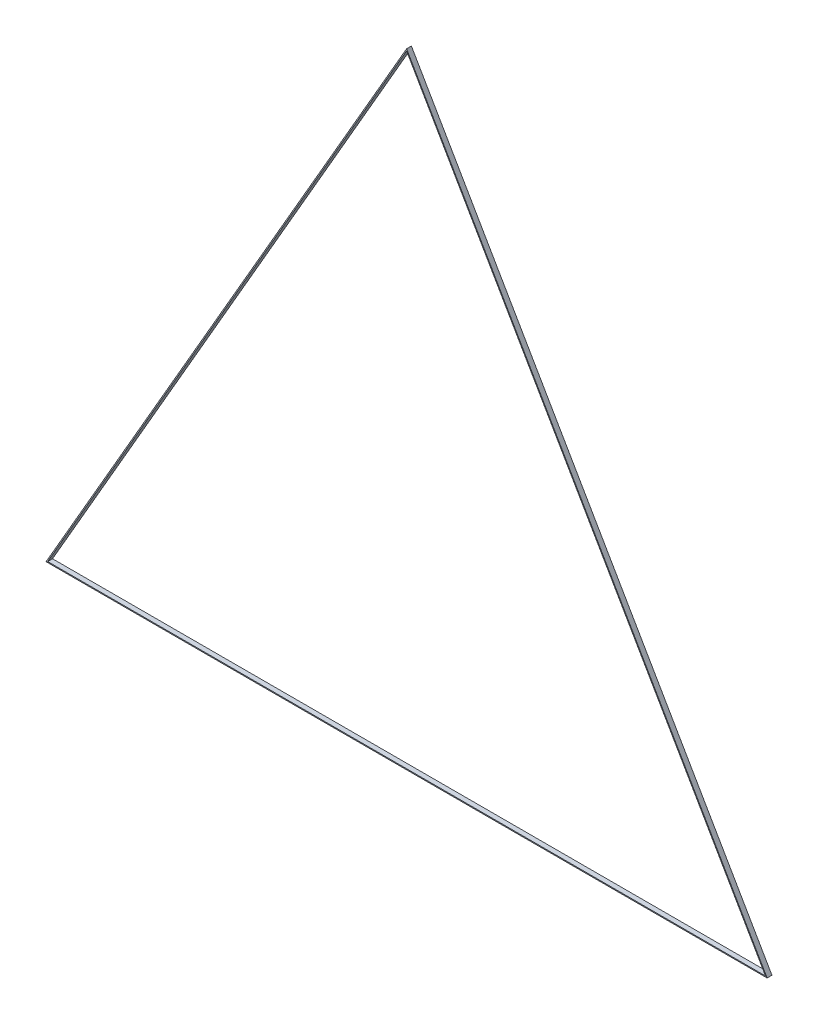
from build123d import *

# Parameters (mm, degrees)
BOSS_EXTRU_1_DEPTH      = 10
ENL_V_MAT_EXTRU_1_DEPTH = 10


with BuildPart() as part:
    # Esquisse1 → Boss.-Extru.1 (new body)
    with BuildSketch(Plane.XY):
        Polygon((-750, 0), (0, 1299.038105677), (750, 0), align=None)
    extrude(amount=BOSS_EXTRU_1_DEPTH)

    # Esquisse2 → Enlèv. mat.-Extru.1 (cut)
    with BuildSketch(Plane.XY.offset(10)):
        Polygon((-746.535898385, 2), (0, 1295.038105677), (746.535898385, 2), align=None)
    extrude(amount=-ENL_V_MAT_EXTRU_1_DEPTH, mode=Mode.SUBTRACT)


solid = part.part
